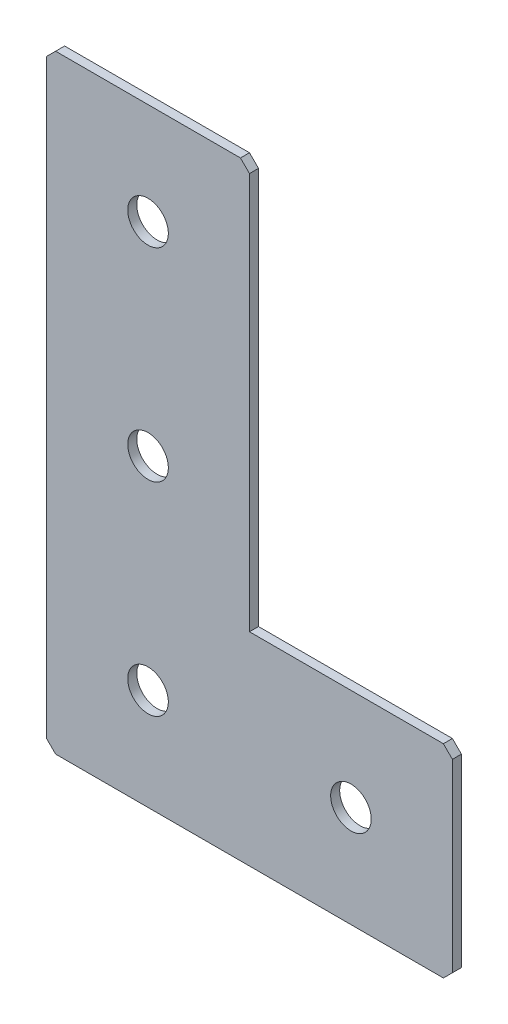
from build123d import *

# Parameters (mm, degrees)
EXTRUDE_1_DEPTH   = 2
HOLE_WIZARD_M81_D = 9
CHAMFER_1_SIZE    = 2


with BuildPart() as part:
    # Эскиз1 → Бобышка-Вытянуть1 (new body)
    with BuildSketch(Plane(origin=(0, 0, 0), x_dir=(1, 0, 0), z_dir=(0, 0, -1))):
        Polygon((0, 0), (0, 135), (90, 135), (90, 90), (45, 90), (45, 0), align=None)
    extrude(amount=EXTRUDE_1_DEPTH)

    # Отверстие с зазором M81 (through all)
    with Locations(Plane(origin=(0, 0, -2), x_dir=(1, 0, 0), z_dir=(0, 0, -1))):
        with Locations((67.5, 112.5), (22.5, 112.5), (22.5, 67.5), (22.5, 22.5)):
            Hole(HOLE_WIZARD_M81_D / 2)

    # Фаска1
    chamfer_1_edges = [part.edges().sort_by_distance(p)[0] for p in [
        (0, 0, -1),
        (0, -135, -1),
        (90, -135, -1),
        (90, -90, -1),
        (45, 0, -1),
    ]]
    chamfer(chamfer_1_edges, length=CHAMFER_1_SIZE)


solid = part.part
